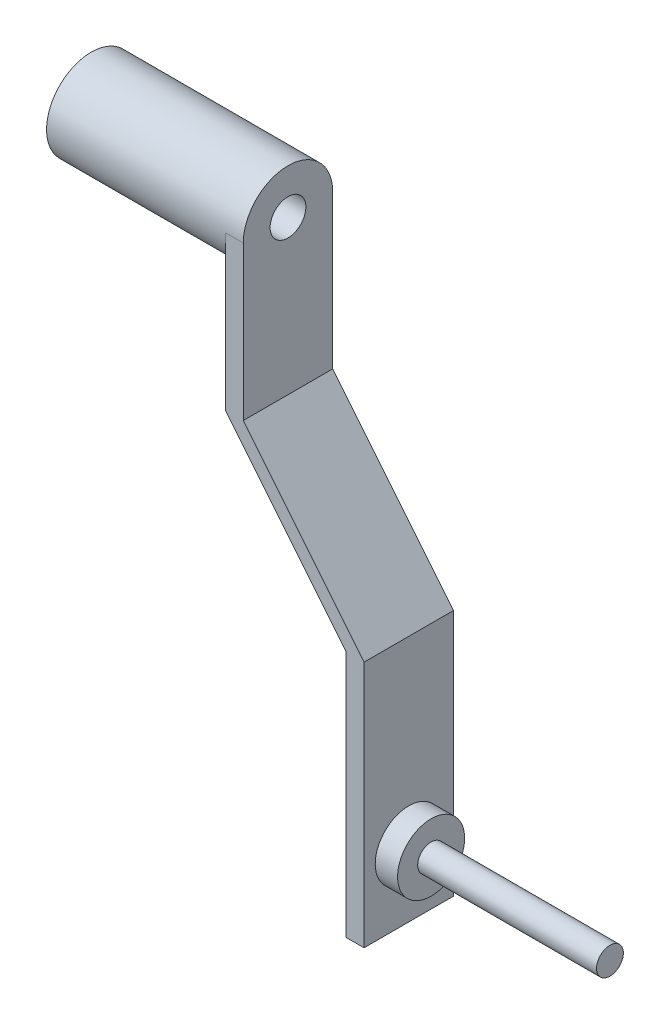
from build123d import *

# Parameters (mm, degrees)
SKETCH1_R           = 5
BOSS_EXTRUDE1_DEPTH = 20
BOSS_EXTRUDE2_DEPTH = 2
SKETCH3_R           = 2
CUT_EXTRUDE1_DEPTH  = 23
BOSS_EXTRUDE3_DEPTH = 5
SKETCH5_W           = 2
SKETCH5_H           = 27.667167525
BOSS_EXTRUDE4_DEPTH = 5
SKETCH6_R           = 3.75
BOSS_EXTRUDE5_DEPTH = 2.5
SKETCH7_R           = 1.5
BOSS_EXTRUDE6_DEPTH = 20


with BuildPart() as part:
    # Sketch1 → Boss-Extrude1 (new body)
    with BuildSketch(Plane(origin=(0, 0, 0), x_dir=(0, 0, -1), z_dir=(1, 0, 0))):
        Circle(SKETCH1_R)
    extrude(amount=BOSS_EXTRUDE1_DEPTH)

    # Sketch2 → Boss-Extrude2 (add)
    with BuildSketch(Plane(origin=(20, 0, 0), x_dir=(0, 0, -1), z_dir=(1, 0, 0))):
        with BuildLine():
            Line((-5, 0), (-5, -17.185208198))
            Line((-5, -17.185208198), (5, -17.185208198))
            Line((5, -17.185208198), (5, 0))
            ThreePointArc((5, 0), (0, 5), (-5, 0))
        make_face()
    extrude(amount=BOSS_EXTRUDE2_DEPTH)

    # Sketch3 → Cut-Extrude1 (cut, through all)
    with BuildSketch(Plane(origin=(22, 0, 0), x_dir=(0, 0, -1), z_dir=(1, 0, 0))):
        Circle(SKETCH3_R)
    extrude(amount=-CUT_EXTRUDE1_DEPTH, mode=Mode.SUBTRACT)

    # Sketch4 → Boss-Extrude3 (add, symmetric)
    with BuildSketch(Plane.XY):
        Polygon((20, -17.185208198), (33.506911319, -33.834240512), (35.506911319, -33.834240512), (22, -17.185208198), align=None)
    extrude(amount=BOSS_EXTRUDE3_DEPTH, both=True)

    # Sketch5 → Boss-Extrude4 (add, symmetric)
    with BuildSketch(Plane.XY):
        with Locations((34.506911319, -47.667824275)):
            Rectangle(SKETCH5_W, SKETCH5_H)
    extrude(amount=BOSS_EXTRUDE4_DEPTH, both=True)

    # Sketch6 → Boss-Extrude5 (add)
    with BuildSketch(Plane(origin=(35.506911319, 0, 0), x_dir=(0, 0, -1), z_dir=(1, 0, 0))):
        with Locations((0, -54.001408037)):
            Circle(SKETCH6_R)
    extrude(amount=BOSS_EXTRUDE5_DEPTH)

    # Sketch7 → Boss-Extrude6 (add)
    with BuildSketch(Plane(origin=(38.006911319, 0, 0), x_dir=(0, 0, -1), z_dir=(1, 0, 0))):
        with Locations((0, -54.001408037)):
            Circle(SKETCH7_R)
    extrude(amount=BOSS_EXTRUDE6_DEPTH)


solid = part.part
